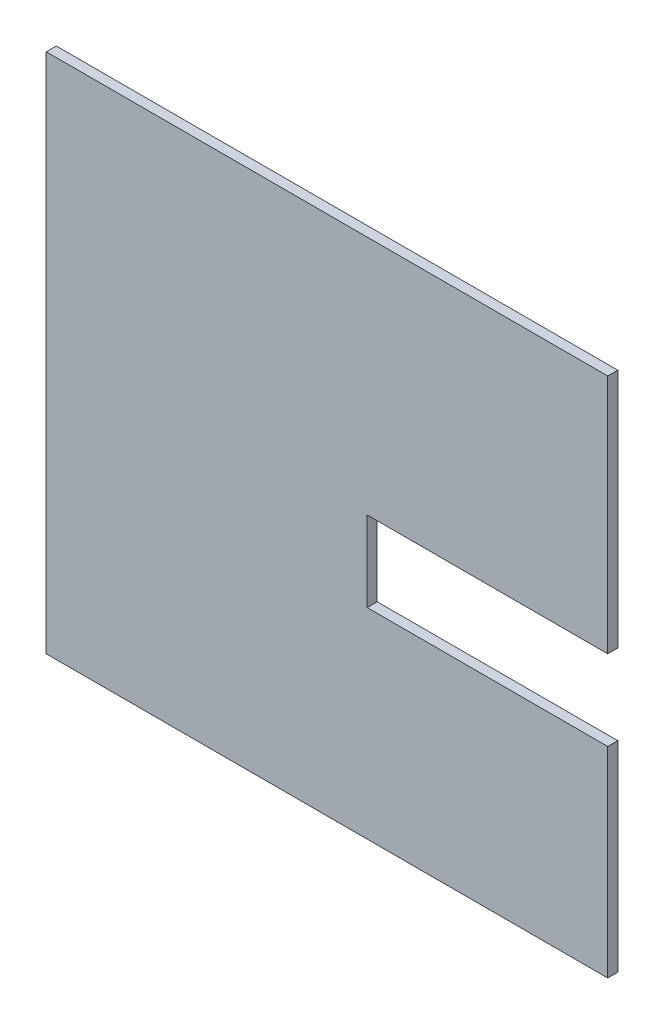
from build123d import *

# Parameters (mm, degrees)
SKETCH1_W           = 355.6
SKETCH1_H           = 330.2
BOSS_EXTRUDE1_DEPTH = 3.175
SKETCH3_W           = 152.4
SKETCH3_H           = 50.8
CUT_EXTRUDE1_DEPTH  = 7.35


with BuildPart() as part:
    # Sketch1 → Boss-Extrude1 (new body, symmetric)
    with BuildSketch(Plane.XY):
        Rectangle(SKETCH1_W, SKETCH1_H)
    extrude(amount=BOSS_EXTRUDE1_DEPTH, both=True)

    # Sketch3 → Cut-Extrude1 (cut, through all)
    with BuildSketch(Plane.XY.offset(3.175)):
        with Locations((101.6, -12.7)):
            Rectangle(SKETCH3_W, SKETCH3_H)
    extrude(amount=-CUT_EXTRUDE1_DEPTH, mode=Mode.SUBTRACT)


solid = part.part
